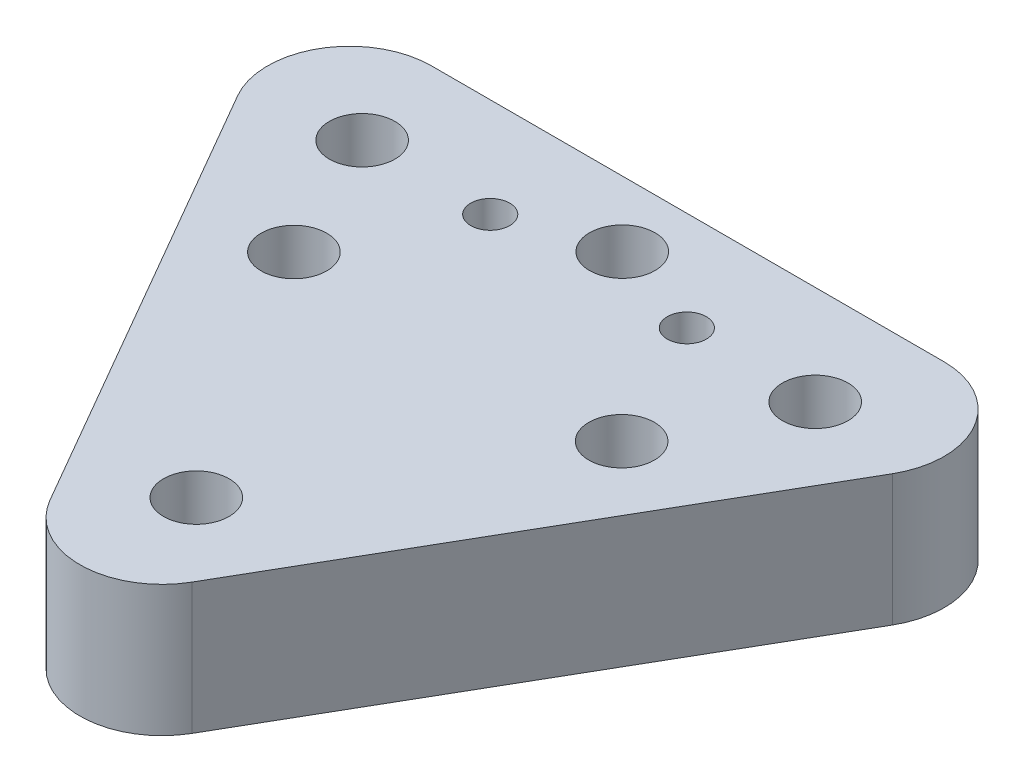
from build123d import *

# Parameters (mm, degrees)
SKETCH1_R                    = 1
EXTRUDE1_DEPTH               = 4
SKETCH1_3_R                  = 2.38125
EXTRUDE4_DEPTH               = 2
M2X0_4_TAPPED_HOLE1_D        = 1.6
M2X0_4_TAPPED_HOLE1_DEPTH    = 3
M2X0_4_TAPPED_HOLE1_TIP      = 0.480688495
F_2_0_2_DIAMETER_HOLE1_D     = 2
F_2_0_2_DIAMETER_HOLE1_DEPTH = 10
F_2_0_2_DIAMETER_HOLE1_TIP   = 0.600860619
F_0_80_TAPPED_HOLE2_D        = 1.19126
F_0_80_TAPPED_HOLE2_DEPTH    = 4


with BuildPart() as part:
    # Sketch1 → Extrude1 (new body)
    with BuildSketch(Plane(origin=(0, 0, 0), x_dir=(1, 0, 0), z_dir=(0, 1, 0))):
        with BuildLine():
            Line((-5.186041147, 3.316192399), (2.637731834, -10.234979911))
            ThreePointArc((2.637731834, -10.234979911), (4.802795343, -11.484979911), (6.967858853, -10.234979911))
            Line((6.967858853, -10.234979911), (14.791631834, 3.316192399))
            ThreePointArc((14.791631834, 3.316192399), (14.791631834, 5.816192399), (12.626568324, 7.066192399))
            Line((12.626568324, 7.066192399), (-3.020977638, 7.066192399))
            ThreePointArc((-3.020977638, 7.066192399), (-5.186041147, 5.816192399), (-5.186041147, 3.316192399))
        make_face()
        with Locations((-2.110635714, 4.040606244)):
            Circle(SKETCH1_R, mode=Mode.SUBTRACT)
        with Locations((11.7162264, 4.040606244)):
            Circle(SKETCH1_R, mode=Mode.SUBTRACT)
        with Locations((4.802795343, -7.933807601)):
            Circle(SKETCH1_R, mode=Mode.SUBTRACT)
    extrude(amount=EXTRUDE1_DEPTH)

    # Sketch1_3 → Extrude4 (cut)
    with BuildSketch(Plane(origin=(0, 0, 0), x_dir=(1, 0, 0), z_dir=(0, 1, 0))):
        with Locations((4.802795343, -7.933807601)):
            Circle(SKETCH1_3_R)
        with Locations((11.7162264, 4.040606244)):
            Circle(SKETCH1_3_R)
        with Locations((-2.110635714, 4.040606244)):
            Circle(SKETCH1_3_R)
    extrude(amount=EXTRUDE4_DEPTH, mode=Mode.SUBTRACT)

    # M2x0.4 Tapped Hole1
    with Locations(Plane(origin=(4.802795343, 0, -0.049134963), x_dir=(0, 0, -1), z_dir=(0, -1, 0))):
        with Locations((0, 0)):
            Hole(M2X0_4_TAPPED_HOLE1_D / 2, depth=M2X0_4_TAPPED_HOLE1_DEPTH)
            with Locations((0, 0, -(M2X0_4_TAPPED_HOLE1_DEPTH + M2X0_4_TAPPED_HOLE1_TIP / 2))):  # 118° drill point
                Cone(0, M2X0_4_TAPPED_HOLE1_D / 2, M2X0_4_TAPPED_HOLE1_TIP, mode=Mode.SUBTRACT)

    # Ø2.0 (2) Diameter Hole1
    with Locations(Plane(origin=(4.802795343, 0, -5.066192399), x_dir=(0, 0, -1), z_dir=(0, -1, 0))):
        with Locations((0, 0), (-5.02, 5), (-5.02, -5)):
            Hole(F_2_0_2_DIAMETER_HOLE1_D / 2, depth=F_2_0_2_DIAMETER_HOLE1_DEPTH)
            with Locations((0, 0, -(F_2_0_2_DIAMETER_HOLE1_DEPTH + F_2_0_2_DIAMETER_HOLE1_TIP / 2))):  # 118° drill point
                Cone(0, F_2_0_2_DIAMETER_HOLE1_D / 2, F_2_0_2_DIAMETER_HOLE1_TIP, mode=Mode.SUBTRACT)

    # 0-80 Tapped Hole2
    with Locations(Plane(origin=(1.802795343, 4, -4.036192399), x_dir=(0, 0, 1), z_dir=(0, 1, 0))):
        with Locations((0, 0), (0, 6)):
            Hole(F_0_80_TAPPED_HOLE2_D / 2, depth=F_0_80_TAPPED_HOLE2_DEPTH)


solid = part.part
